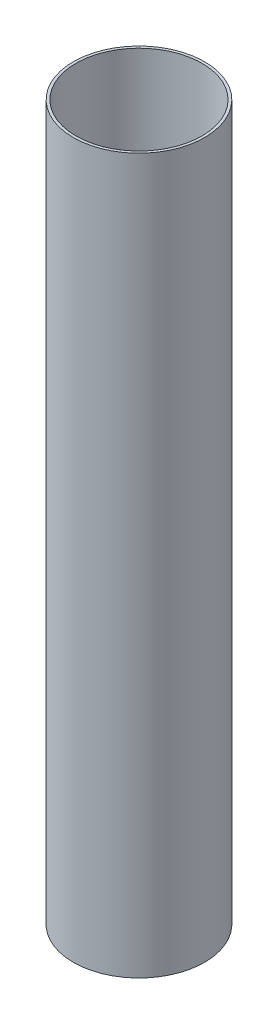
from build123d import *

# Parameters (mm, degrees)
SKETCH1_R           = 39.7
SKETCH1_R_2         = 38.1
BOSS_EXTRUDE1_DEPTH = 431.8


with BuildPart() as part:
    # Sketch1 → Boss-Extrude1 (new body)
    with BuildSketch(Plane(origin=(0, 0, 0), x_dir=(1, 0, 0), z_dir=(0, 1, 0))):
        Circle(SKETCH1_R)
        Circle(SKETCH1_R_2, mode=Mode.SUBTRACT)
    extrude(amount=BOSS_EXTRUDE1_DEPTH)


solid = part.part
